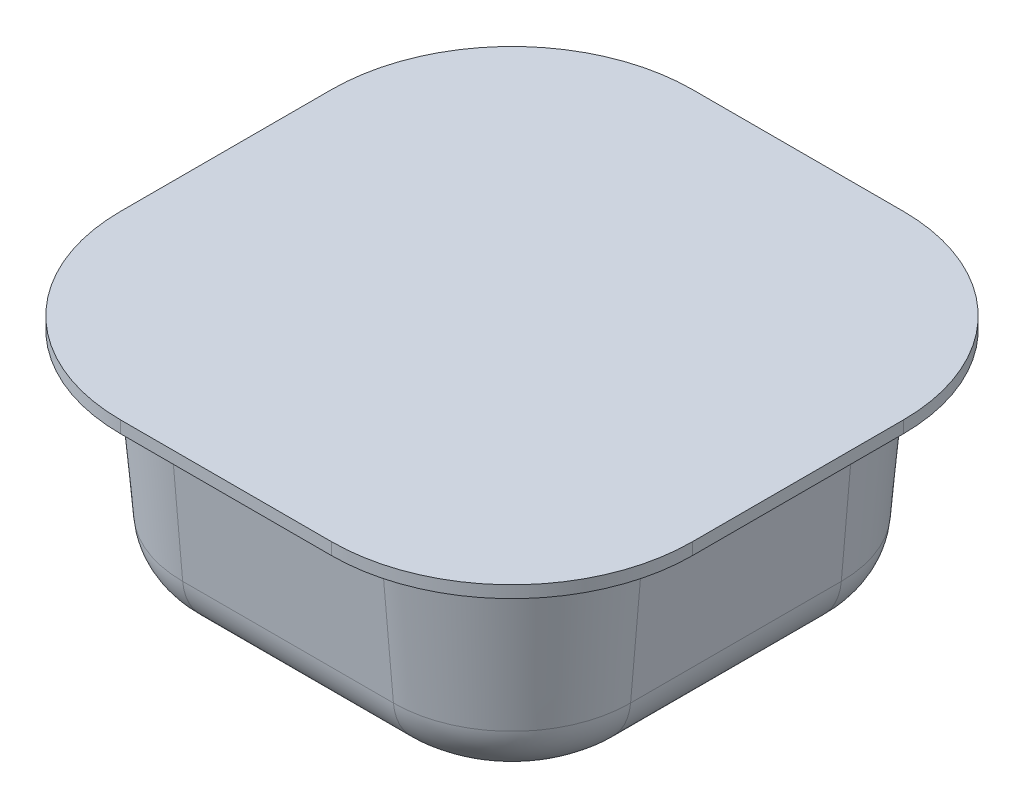
from build123d import *

# Parameters (mm, degrees)
SKETCH1_W           = 48.26
SKETCH1_H           = 48.26
BOSS_EXTRUDE1_DEPTH = 1.016
FILLET1_R           = 15.24
BOSS_EXTRUDE2_DEPTH = 18.034
BOSS_EXTRUDE2_TAPER = 5
FILLET2_R           = 5.08


with BuildPart() as part:
    # Sketch1 → Boss-Extrude1 (new body)
    with BuildSketch(Plane(origin=(0, 19.05, 0), x_dir=(1, 0, 0), z_dir=(0, 1, 0))):
        Rectangle(SKETCH1_W, SKETCH1_H)
    extrude(amount=-BOSS_EXTRUDE1_DEPTH)

    # Fillet1
    fillet1_edges = [part.edges().sort_by_distance(p)[0] for p in [
        (-24.13, 18.542, -24.13),
        (24.13, 18.542, -24.13),
        (24.13, 18.542, 24.13),
        (-24.13, 18.542, 24.13),
    ]]
    fillet(fillet1_edges, radius=FILLET1_R)

    # Sketch2 → Boss-Extrude2 (add)
    with BuildSketch(Plane.XZ.offset(-18.034)):
        with BuildLine():
            Line((8.89, 20.066), (-8.89, 20.066))
            ThreePointArc((-8.89, 20.066), (-16.792625387, 16.792625387), (-20.066, 8.89))
            Line((-20.066, 8.89), (-20.066, -8.89))
            ThreePointArc((-20.066, -8.89), (-16.792625387, -16.792625387), (-8.89, -20.066))
            Line((-8.89, -20.066), (8.89, -20.066))
            ThreePointArc((8.89, -20.066), (16.792625387, -16.792625387), (20.066, -8.89))
            Line((20.066, -8.89), (20.066, 8.89))
            ThreePointArc((20.066, 8.89), (16.792625387, 16.792625387), (8.89, 20.066))
        make_face()
    extrude(amount=BOSS_EXTRUDE2_DEPTH, taper=BOSS_EXTRUDE2_TAPER)

    # Fillet2
    fillet2_edges = [part.edges().sort_by_distance(p)[0] for p in [
        (18.488229442, 0, 0),
        (15.676973126, 0, -15.676973126),
        (0, 0, -18.488229442),
        (-15.676973126, 0, -15.676973126),
        (-18.488229442, 0, 0),
        (-15.676973126, 0, 15.676973126),
        (0, 0, 18.488229442),
        (15.676973126, 0, 15.676973126),
    ]]
    fillet(fillet2_edges, radius=FILLET2_R)


solid = part.part
